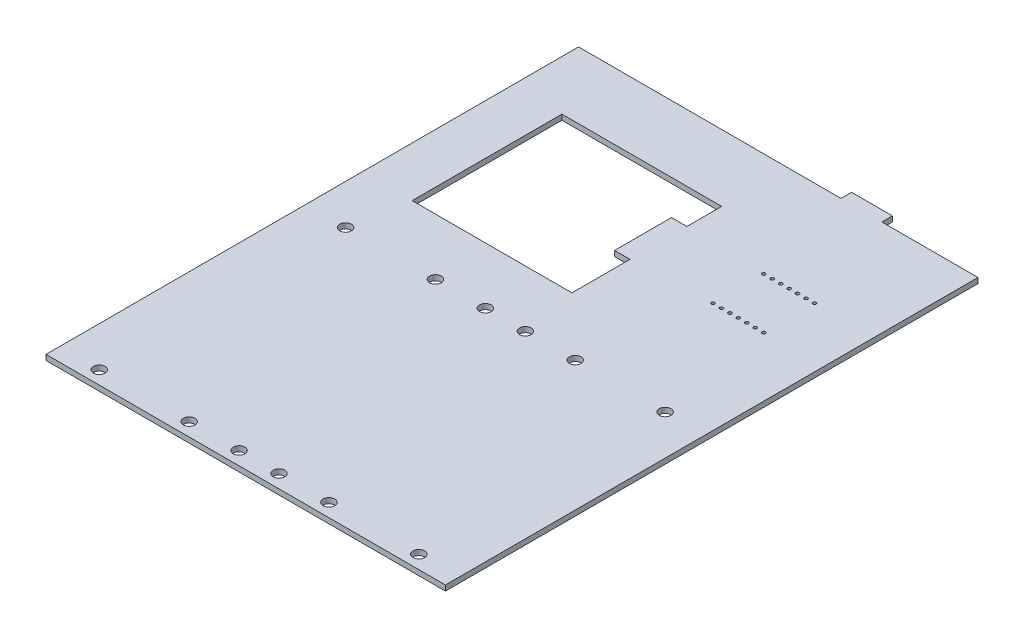
from build123d import *

# Parameters (mm, degrees)
SKETCH1_R           = 0.5
SKETCH1_R_2         = 1.75
BOSS_EXTRUDE2_DEPTH = 1.6


with BuildPart() as part:
    # Sketch1 → Boss-Extrude2 (new body)
    with BuildSketch(Plane(origin=(0, 0, 0), x_dir=(1, 0, 0), z_dir=(0, 1, 0))):
        Polygon((78.84, 0), (0, 0), (0, -160), (120, -160), (120, 0), (91.12, 0), (91.12, 3.176), (78.84, 3.176), align=None)
        with Locations((86.9, -46.51)):
            Circle(SKETCH1_R, mode=Mode.SUBTRACT)
        with Locations((89.44, -46.51)):
            Circle(SKETCH1_R, mode=Mode.SUBTRACT)
        with Locations((91.98, -46.51)):
            Circle(SKETCH1_R, mode=Mode.SUBTRACT)
        with Locations((94.52, -46.51)):
            Circle(SKETCH1_R, mode=Mode.SUBTRACT)
        with Locations((97.06, -46.51)):
            Circle(SKETCH1_R, mode=Mode.SUBTRACT)
        with Locations((99.6, -46.51)):
            Circle(SKETCH1_R, mode=Mode.SUBTRACT)
        with Locations((102.14, -46.51)):
            Circle(SKETCH1_R, mode=Mode.SUBTRACT)
        with Locations((86.9, -31.27)):
            Circle(SKETCH1_R, mode=Mode.SUBTRACT)
        with Locations((89.44, -31.27)):
            Circle(SKETCH1_R, mode=Mode.SUBTRACT)
        with Locations((91.98, -31.27)):
            Circle(SKETCH1_R, mode=Mode.SUBTRACT)
        with Locations((94.52, -31.27)):
            Circle(SKETCH1_R, mode=Mode.SUBTRACT)
        with Locations((97.06, -31.27)):
            Circle(SKETCH1_R, mode=Mode.SUBTRACT)
        with Locations((99.6, -31.27)):
            Circle(SKETCH1_R, mode=Mode.SUBTRACT)
        with Locations((102.14, -31.27)):
            Circle(SKETCH1_R, mode=Mode.SUBTRACT)
        Polygon((63, -47.55), (63, -65), (15, -65), (15, -20), (63, -20), (63, -30.45), (58.372, -30.45), (58.372, -47.55), align=None, mode=Mode.SUBTRACT)
        with Locations((12, -82)):
            Circle(SKETCH1_R_2, mode=Mode.SUBTRACT)
        with Locations((12, -156)):
            Circle(SKETCH1_R_2, mode=Mode.SUBTRACT)
        with Locations((54, -82)):
            Circle(SKETCH1_R_2, mode=Mode.SUBTRACT)
        with Locations((39, -82)):
            Circle(SKETCH1_R_2, mode=Mode.SUBTRACT)
        with Locations((39, -156)):
            Circle(SKETCH1_R_2, mode=Mode.SUBTRACT)
        with Locations((54, -156)):
            Circle(SKETCH1_R_2, mode=Mode.SUBTRACT)
        with Locations((108, -82)):
            Circle(SKETCH1_R_2, mode=Mode.SUBTRACT)
        with Locations((108, -156)):
            Circle(SKETCH1_R_2, mode=Mode.SUBTRACT)
        with Locations((66, -82)):
            Circle(SKETCH1_R_2, mode=Mode.SUBTRACT)
        with Locations((81, -156)):
            Circle(SKETCH1_R_2, mode=Mode.SUBTRACT)
        with Locations((81, -82)):
            Circle(SKETCH1_R_2, mode=Mode.SUBTRACT)
        with Locations((66, -156)):
            Circle(SKETCH1_R_2, mode=Mode.SUBTRACT)
    extrude(amount=BOSS_EXTRUDE2_DEPTH)


solid = part.part
